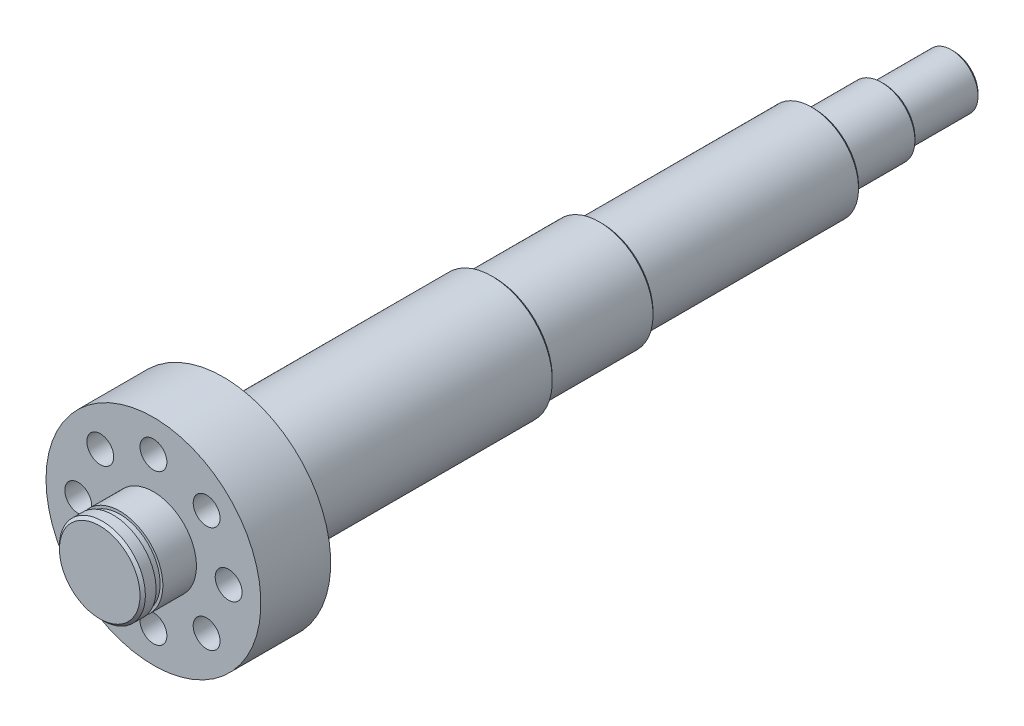
from build123d import *

# Parameters (mm, degrees)
SKETCH_1_R               = 16
EXTRUDE_1_DEPTH          = 20
SKETCH_2_R               = 40
EXTRUDE_2_DEPTH          = 26
SKETCH_3_W               = 1
SKETCH_3_H               = 2.5
SKETCH_4_R               = 5
CUT_EXTRUDE_1_DEPTH      = 8
PATTERN_CIRCULAR_1_COUNT = 8
CHAMFER_1_SIZE           = 1
SKETCH_5_R               = 22.5
EXTRUDE_3_DEPTH          = 101
SKETCH_6_R               = 20
EXTRUDE_4_DEPTH          = 40
SKETCH_7_R               = 17.5
EXTRUDE_5_DEPTH          = 79
SKETCH_8_R               = 12.5
EXTRUDE_6_DEPTH          = 26
SKETCH_9_R               = 10
EXTRUDE_7_DEPTH          = 26
CHAMFER_2_SIZE           = 1
CHAMFER_3_SIZE           = 1
SKETCH_10_R              = 2.5
CUT_EXTRUDE_2_DEPTH      = 7


with BuildPart() as part:
    # 草图1 → 凸台-拉伸1 (new body)
    with BuildSketch(Plane.XY):
        Circle(SKETCH_1_R)
    extrude(amount=EXTRUDE_1_DEPTH)

    # 草图2 → 凸台-拉伸2 (add)
    with BuildSketch(Plane(origin=(0, 0, 0), x_dir=(-1, 0, 0), z_dir=(0, 0, -1))):
        Circle(SKETCH_2_R)
    extrude(amount=EXTRUDE_2_DEPTH)

    # 草图3 → 切除-旋转1 (revolve, cut)
    with BuildSketch(Plane(origin=(0, 0, 0), x_dir=(1, 0, 0), z_dir=(0, 1, 0))):
        with Locations((15.5, -13.75)):
            Rectangle(SKETCH_3_W, SKETCH_3_H)
    revolve(axis=Axis((0, 0, 0), (0, 0, 1)), mode=Mode.SUBTRACT)

    # 草图4 → 切除-拉伸1 (cut)
    with BuildSketch(Plane.XY):
        with Locations((28, 0)):
            Circle(SKETCH_4_R)
    cut_extrude_1 = extrude(amount=-CUT_EXTRUDE_1_DEPTH, mode=Mode.SUBTRACT)

    # 阵列(圆周)1: 切除-拉伸1 ×8 about axis
    pattern_circular_1_axis = Axis((0, 0, 0), (0, 0, 1))
    for i in range(1, PATTERN_CIRCULAR_1_COUNT):
        add(cut_extrude_1.rotate(pattern_circular_1_axis, i * 360 / PATTERN_CIRCULAR_1_COUNT), mode=Mode.SUBTRACT)

    # 倒角1
    chamfer_1_edges = [part.edges().sort_by_distance(p)[0] for p in [
        (-16, 0, 20),
    ]]
    chamfer(chamfer_1_edges, length=CHAMFER_1_SIZE)

    # 草图5 → 凸台-拉伸3 (add)
    with BuildSketch(Plane(origin=(0, 0, -26), x_dir=(-1, 0, 0), z_dir=(0, 0, -1))):
        Circle(SKETCH_5_R)
    extrude(amount=EXTRUDE_3_DEPTH)

    # 草图6 → 凸台-拉伸4 (add)
    with BuildSketch(Plane(origin=(0, 0, -127), x_dir=(-1, 0, 0), z_dir=(0, 0, -1))):
        Circle(SKETCH_6_R)
    extrude(amount=EXTRUDE_4_DEPTH)

    # 草图7 → 凸台-拉伸5 (add)
    with BuildSketch(Plane(origin=(0, 0, -167), x_dir=(-1, 0, 0), z_dir=(0, 0, -1))):
        Circle(SKETCH_7_R)
    extrude(amount=EXTRUDE_5_DEPTH)

    # 草图8 → 凸台-拉伸6 (add)
    with BuildSketch(Plane(origin=(0, 0, -246), x_dir=(-1, 0, 0), z_dir=(0, 0, -1))):
        Circle(SKETCH_8_R)
    extrude(amount=EXTRUDE_6_DEPTH)

    # 草图9 → 凸台-拉伸7 (add)
    with BuildSketch(Plane(origin=(0, 0, -272), x_dir=(-1, 0, 0), z_dir=(0, 0, -1))):
        Circle(SKETCH_9_R)
    extrude(amount=EXTRUDE_7_DEPTH)

    # 倒角2
    chamfer_2_edges = [part.edges().sort_by_distance(p)[0] for p in [
        (20, 0, -167),
        (17.5, 0, -246),
        (12.5, 0, -272),
        (10, 0, -298),
    ]]
    chamfer(chamfer_2_edges, length=CHAMFER_2_SIZE)

    # 倒角3
    chamfer_3_edges = [part.edges().sort_by_distance(p)[0] for p in [
        (22.5, 0, -127),
    ]]
    chamfer(chamfer_3_edges, length=CHAMFER_3_SIZE)

    # 草图10 → 切除-拉伸2 (cut)
    with BuildSketch(Plane(origin=(0, 0, -298), x_dir=(-1, 0, 0), z_dir=(0, 0, -1))):
        with Locations((-6, 0.24134819)):
            Circle(SKETCH_10_R)
        with Locations((6, 0)):
            Circle(SKETCH_10_R)
    extrude(amount=-CUT_EXTRUDE_2_DEPTH, mode=Mode.SUBTRACT)


solid = part.part
